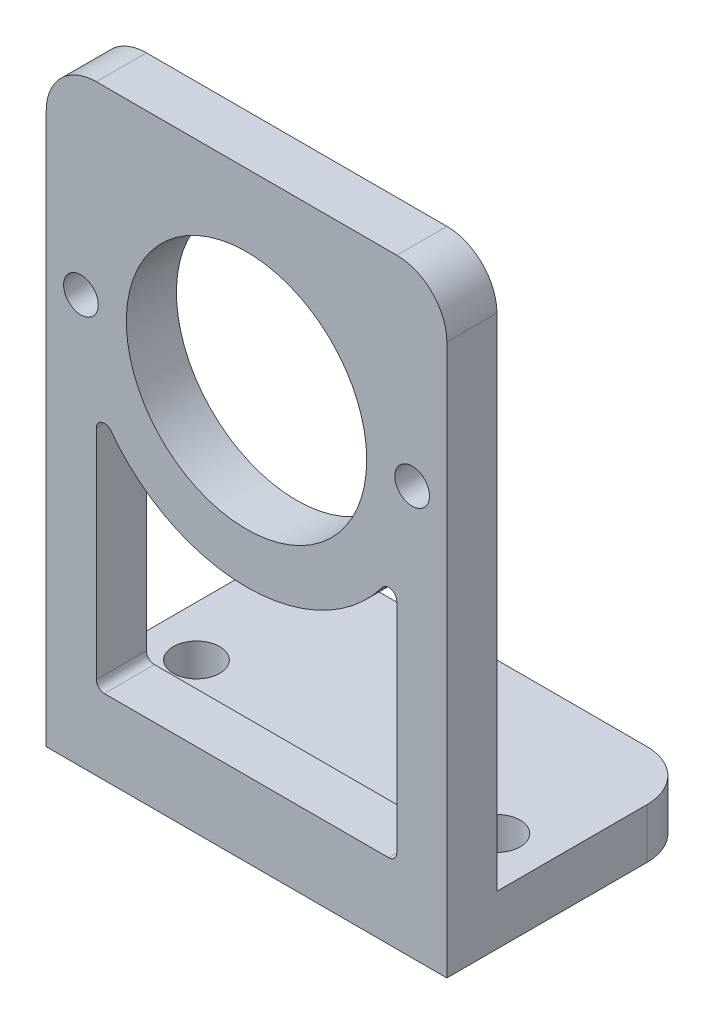
from build123d import *

# Parameters (mm, degrees)
BOSS_EXTRUDE1_DEPTH   = 12.7
SKETCH2_R             = 7.62
CUT_EXTRUDE1_DEPTH    = 16.875
FILLET1_R             = 3.175
F_4_CLEARANCE_HOLE1_D = 2.9464
M2_CLEARANCE_HOLE1_D  = 2.2
CUT_EXTRUDE2_DEPTH    = 16.875
FILLET2_R             = 0.508


with BuildPart() as part:
    # Sketch1 → Boss-Extrude1 (new body, symmetric)
    with BuildSketch(Plane(origin=(0, 0, 0), x_dir=(0, 0, -1), z_dir=(1, 0, 0))):
        Polygon((0, 38.1), (0, 0), (15.875, 0), (15.875, 3.175), (3.175, 3.175), (3.175, 38.1), align=None)
    extrude(amount=BOSS_EXTRUDE1_DEPTH, both=True)

    # Sketch2 → Cut-Extrude1 (cut, through all)
    with BuildSketch(Plane.XY):
        with Locations((0, 25.908)):
            Circle(SKETCH2_R)
    extrude(amount=-CUT_EXTRUDE1_DEPTH, mode=Mode.SUBTRACT)

    # Fillet1
    fillet1_edges = [part.edges().sort_by_distance(p)[0] for p in [
        (12.7, 1.5875, -15.875),
        (12.7, 38.1, -1.5875),
        (-12.7, 1.5875, -15.875),
        (-12.7, 38.1, -1.5875),
    ]]
    fillet(fillet1_edges, radius=FILLET1_R)

    # #4 Clearance Hole1 (through all)
    with Locations(Plane(origin=(0, 3.175, 0), x_dir=(1, 0, 0), z_dir=(0, 1, 0))):
        with Locations((-9.525, 6.35), (0, 12.7), (9.525, 6.35)):
            Hole(F_4_CLEARANCE_HOLE1_D / 2)

    # M2 Clearance Hole1 (through all)
    with Locations(Plane(origin=(32.851265871, 6.645872946, 0), x_dir=(0, 1, 0), z_dir=(0, 0, 1))):
        with Locations((19.262127054, 22.351265871), (19.262127054, 43.351265871)):
            Hole(M2_CLEARANCE_HOLE1_D / 2)

    # Sketch7 → Cut-Extrude2 (cut, through all)
    with BuildSketch(Plane.XY):
        with BuildLine():
            Line((-9.525, 20.828), (-9.525, 4.7625))
            Line((-9.525, 4.7625), (9.525, 4.7625))
            Line((9.525, 4.7625), (9.525, 20.828))
            ThreePointArc((9.525, 20.828), (0, 15.113), (-9.525, 20.828))
        make_face()
    extrude(amount=-CUT_EXTRUDE2_DEPTH, mode=Mode.SUBTRACT)

    # Fillet2
    fillet2_edges = [part.edges().sort_by_distance(p)[0] for p in [
        (-9.525, 20.828, -1.5875),
        (9.525, 20.828, -1.5875),
        (9.525, 4.7625, -1.5875),
        (-9.525, 4.7625, -1.5875),
    ]]
    fillet(fillet2_edges, radius=FILLET2_R)


solid = part.part
